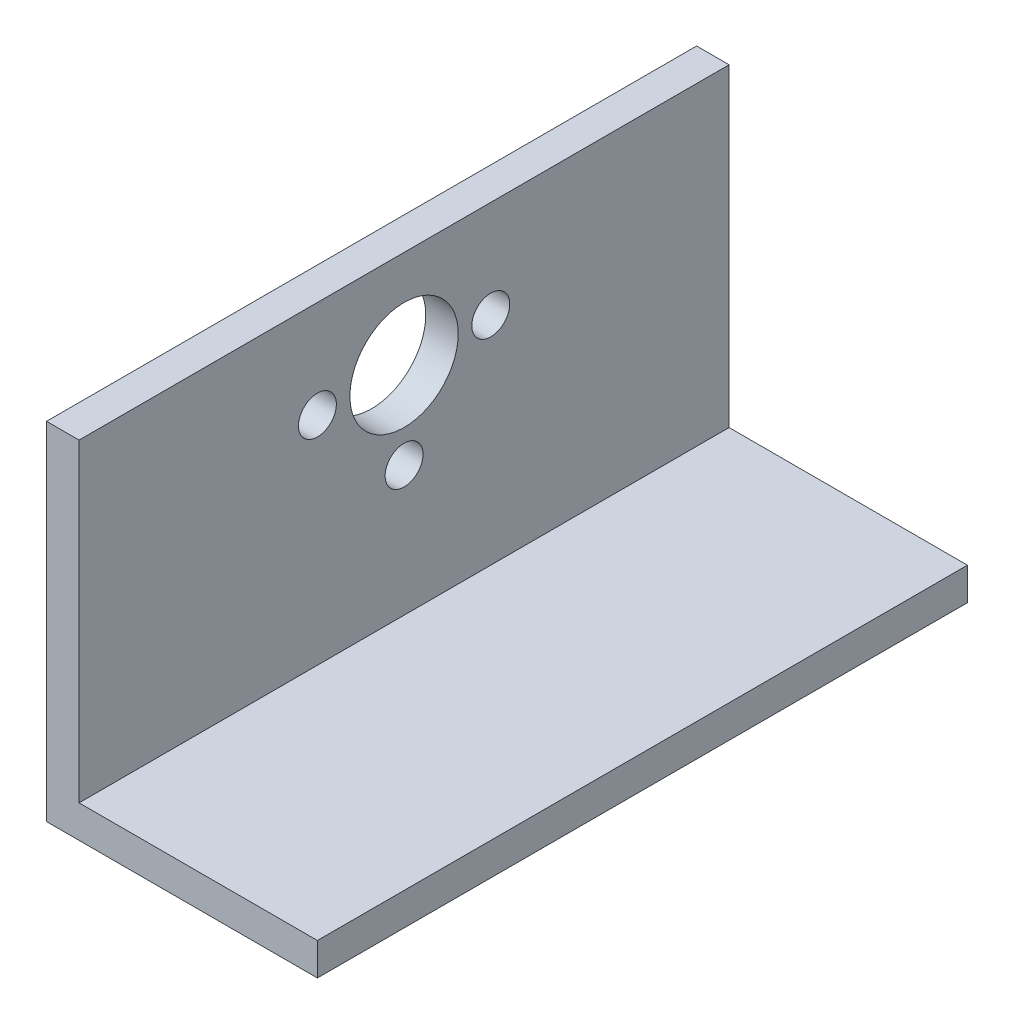
from build123d import *

# Parameters (mm, degrees)
BOSS_EXTRUDE1_DEPTH            = 60
HOLE_FOR_M5_300_SC_NUTS_SP_1_D = 10
HOLE_FOR_M5_300_SC_NUTS_SP_2_D = 3.5


with BuildPart() as part:
    # Sketch1 → Boss-Extrude1 (new body)
    with BuildSketch(Plane.XY):
        Polygon((-7.897485035, 31.347562808), (-7.897485035, 2.347562808), (14.102514965, 2.347562808), (14.102514965, -0.652437192), (-10.897485035, -0.652437192), (-10.897485035, 31.347562808), align=None)
    extrude(amount=BOSS_EXTRUDE1_DEPTH)

    # Hole for M5 300® SC Nuts (SP)1 (through all)
    with Locations(Plane(origin=(-7.897485035, 0, 0), x_dir=(0, 0, -1), z_dir=(1, 0, 0))):
        with Locations((-30, 22.347562808)):
            Hole(HOLE_FOR_M5_300_SC_NUTS_SP_1_D / 2)

    # Hole for M5 300® SC Nuts (SP)2 (through all)
    with Locations(Plane(origin=(-7.897485035, 0, 0), x_dir=(0, 0, -1), z_dir=(1, 0, 0))):
        with Locations((-22, 22.347562808), (-38, 22.347562808), (-30, 14.347562808)):
            Hole(HOLE_FOR_M5_300_SC_NUTS_SP_2_D / 2)


solid = part.part
